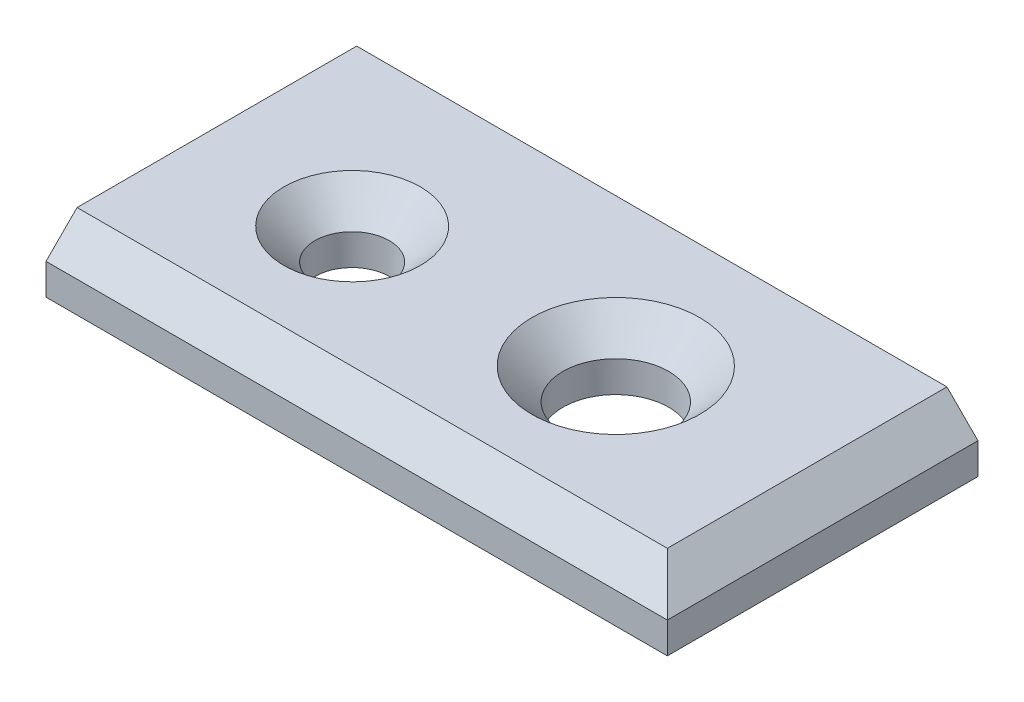
from build123d import *

# Parameters (mm, degrees)
SKIZZE1_W                       = 100
SKIZZE1_H                       = 50
AUFSATZ_LINEAR_AUSTRAGEN1_DEPTH = 10
SKIZZE2_R                       = 5.979005814
SCHNITT_LINEAR_AUSTRAGEN1_DEPTH = 11
FASE1_SIZE                      = 5
SKIZZE3_R                       = 8.504790413
SCHNITT_MIT_EXTRA_FASE_DEPTH    = 11
FASE2_SIZE                      = 5


with BuildPart() as part:
    # Skizze1 → Aufsatz-Linear austragen1 (new body)
    with BuildSketch(Plane(origin=(0, 0, 0), x_dir=(1, 0, 0), z_dir=(0, 1, 0))):
        with Locations((50, 25)):
            Rectangle(SKIZZE1_W, SKIZZE1_H)
    extrude(amount=AUFSATZ_LINEAR_AUSTRAGEN1_DEPTH)

    # Skizze2 → Schnitt-Linear austragen1 (cut, through all)
    with BuildSketch(Plane(origin=(0, 10, 0), x_dir=(1, 0, 0), z_dir=(0, 1, 0))):
        with Locations(Location((24.734846156, 24.536515152, 0), (0, 0, 270))):  # turned: the seam where the file's is
            Circle(SKIZZE2_R)
    extrude(amount=-SCHNITT_LINEAR_AUSTRAGEN1_DEPTH, mode=Mode.SUBTRACT)

    # Fase1
    fase1_edges = [part.edges().sort_by_distance(p)[0] for p in [
        (100, 10, -25),
        (24.734846156, 10, -30.515520966),
        (50, 10, 0),
    ]]
    chamfer(fase1_edges, length=FASE1_SIZE)

    # Skizze3 → Schnitt mit extra Fase (cut, through all)
    with BuildSketch(Plane(origin=(0, 10, 0), x_dir=(1, 0, 0), z_dir=(0, 1, 0))):
        with Locations(Location((65.440217499, 26.266772753, 0), (0, 0, 270))):  # turned: the seam where the file's is
            Circle(SKIZZE3_R)
    extrude(amount=-SCHNITT_MIT_EXTRA_FASE_DEPTH, mode=Mode.SUBTRACT)

    # Fase2
    fase2_edges = [part.edges().sort_by_distance(p)[0] for p in [
        (65.440217499, 10, -34.771563166),
    ]]
    chamfer(fase2_edges, length=FASE2_SIZE)


solid = part.part
